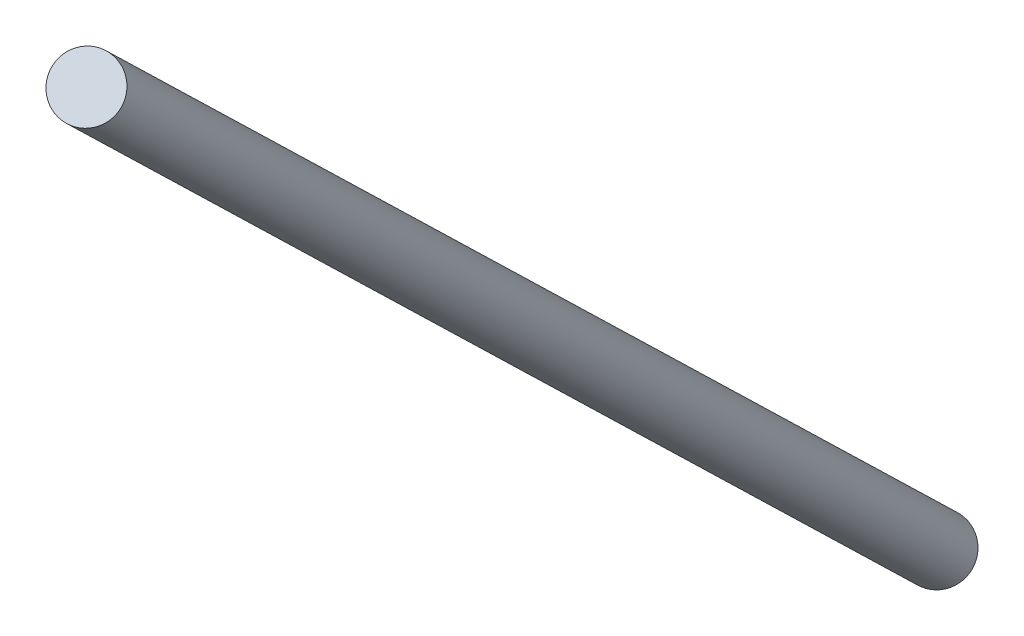
from build123d import *

# Parameters (mm, degrees)
SZKIC1_2_R                  = 2
DODANIE_WYCI_GNI_CIE2_DEPTH = 200


with BuildPart() as part:
    # Szkic1_2 → Dodanie-wyci_gni_cie2 (new body)
    with BuildSketch(Plane(origin=(0, 0, 0), x_dir=(0.541510579, 0.426644859, -0.724389713), z_dir=(0.370465125, 0.65238434, 0.6611734))):
        with Locations(Location((0, 0, 0), (0, 0, 215.661303804))):  # turned: the seam where the file's is
            Circle(SZKIC1_2_R)
    extrude(amount=DODANIE_WYCI_GNI_CIE2_DEPTH)


solid = part.part
